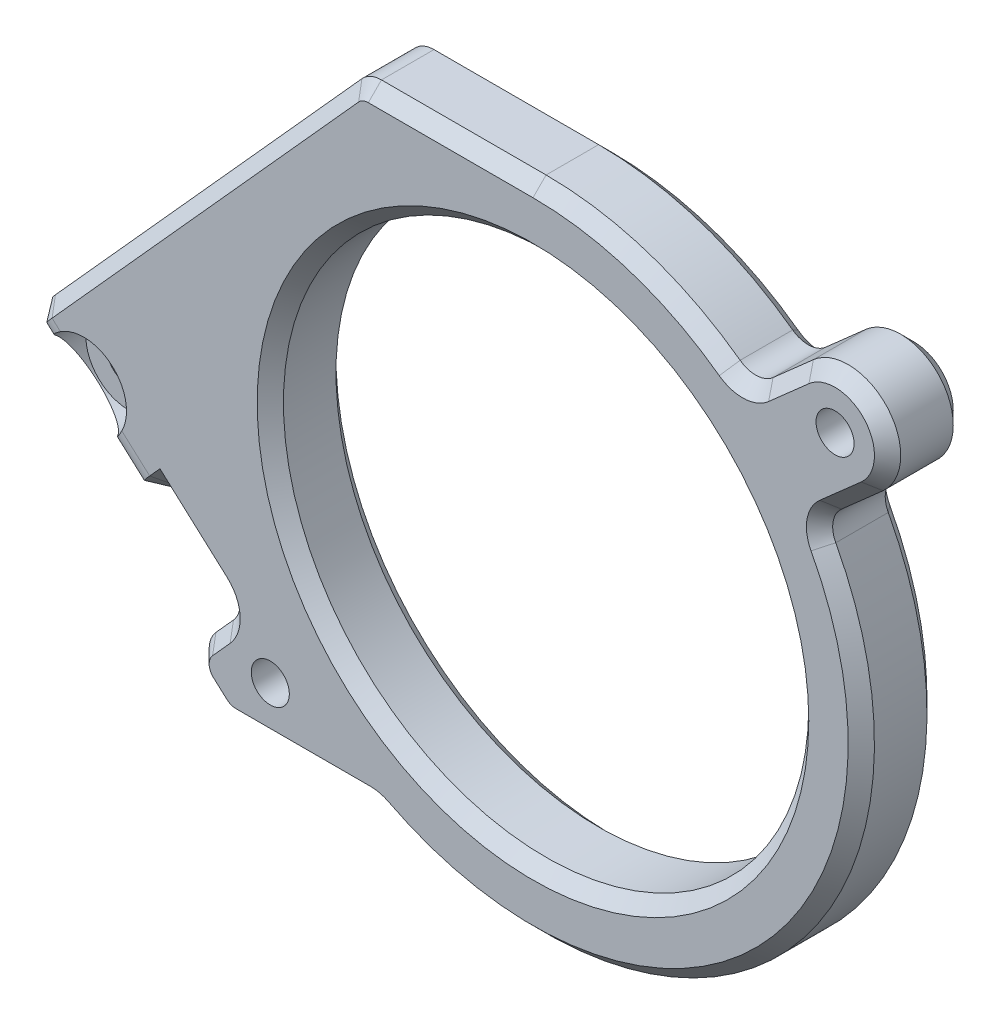
from build123d import *

# Parameters (mm, degrees)
SKETCH_1_W                   = 60
SKETCH_1_H                   = 55
EXTRUDE_1_DEPTH              = 6
HOLE_WIZARD_M4_1_D           = 2.9
HOLE_WIZARD_M4_1_DEPTH       = 10
SKETCH_5_R                   = 20
CUT_EXTRUDE_1_DEPTH          = 7
SKETCH_6_W                   = 60
SKETCH_6_H                   = 55
CUT_EXTRUDE_2_DEPTH          = 7
EXTRUDE_2_DEPTH              = 6
EXTRUDE_3_DEPTH              = 6
EXTRUDE_4_DEPTH              = 4
CUT_EXTRUDE_3_DEPTH          = 11
CUT_EXTRUDE_4_DEPTH          = 6
FILLET_1_R                   = 2
EXTRUDE_5_DEPTH              = 6
CHAMFER_2_SIZE               = 5
FILLET_4_R                   = 2
CHAMFER_3_SIZE               = 1
HOLE_WIZARD_M3_2_D           = 3.3
HOLE_WIZARD_M3_2_DEPTH       = 10
HOLE_WIZARD_M3_2_CBORE_D     = 6.5
HOLE_WIZARD_M3_2_CBORE_DEPTH = 3.4
HOLE_WIZARD_M3_2_TIP         = 0.991420021


with BuildPart() as part:
    # ｽｹｯﾁ1 → ﾎﾞｽ - 押し出し1 (new body)
    with BuildSketch(Plane.XY):
        Rectangle(SKETCH_1_W, SKETCH_1_H)
    extrude(amount=EXTRUDE_1_DEPTH)

    # M4 すきま穴1
    with Locations(Plane.XY.offset(6)):
        with Locations((-20, -18), (23, 20)):
            Hole(HOLE_WIZARD_M4_1_D / 2, depth=HOLE_WIZARD_M4_1_DEPTH)

    # ｽｹｯﾁ5 → ｶｯﾄ - 押し出し1 (cut, through all)
    with BuildSketch(Plane.XY.offset(6)):
        Circle(SKETCH_5_R)
    extrude(amount=-CUT_EXTRUDE_1_DEPTH, mode=Mode.SUBTRACT)

    # ｽｹｯﾁ6 → ｶｯﾄ - 押し出し2 (cut, through all)
    with BuildSketch(Plane.XY.offset(6)):
        Rectangle(SKETCH_6_W, SKETCH_6_H)
        with BuildLine():
            ThreePointArc((-17.351208814, -20.997316342), (-22.997316342, -20.648791186), (-22.648791186, -15.002683658))
            Line((-22.648791186, -15.002683658), (-21.007829355, -13.552531342))
            ThreePointArc((-21.007829355, -13.552531342), (-16.554944912, 18.733227137), (16.03335661, 19.181539975))
            Line((16.03335661, 19.181539975), (20.351208814, 22.997316342))
            ThreePointArc((20.351208814, 22.997316342), (25.997316342, 22.648791186), (25.648791186, 17.002683658))
            Line((25.648791186, 17.002683658), (21.271672672, 13.134532414))
            ThreePointArc((21.271672672, 13.134532414), (24.04986296, 6.826718948), (25, 0))
            ThreePointArc((25, 0), (10.810307191, -22.541900062), (-15.650980674, -19.494789148))
            Line((-15.650980674, -19.494789148), (-17.351208814, -20.997316342))
        make_face(mode=Mode.SUBTRACT)
    extrude(amount=-CUT_EXTRUDE_2_DEPTH, mode=Mode.SUBTRACT)

    # ｽｹｯﾁ7 → ﾎﾞｽ - 押し出し2 (add)
    with BuildSketch(Plane.XY.offset(6)):
        with BuildLine():
            Line((0, 25), (-21.5, 25))
            Line((-21.5, 25), (-21.5, 12.757350822))
            ThreePointArc((-21.5, 12.757350822), (-12.370655388, 21.724798855), (0, 25))
        make_face()
        with BuildLine():
            ThreePointArc((-17.351208814, -20.997316342), (-18.583890076, -21.74094008), (-20, -22))
            Line((-20, -22), (-11.874342087, -22))
            ThreePointArc((-11.874342087, -22), (-13.819546614, -20.833149819), (-15.650980674, -19.494789148))
            Line((-15.650980674, -19.494789148), (-17.351208814, -20.997316342))
        make_face()
        with BuildLine():
            ThreePointArc((-21.007829355, -13.552531342), (-21.25763315, -13.157242601), (-21.5, -12.757350822))
            Line((-21.5, -12.757350822), (-21.5, -13.987472843))
            Line((-21.5, -13.987472843), (-21.007829355, -13.552531342))
        make_face()
    extrude(amount=-EXTRUDE_2_DEPTH)

    # ｽｹｯﾁ8 → ﾎﾞｽ - 押し出し3 (add)
    with BuildSketch(Plane.XY.offset(6)):
        with BuildLine():
            Line((-21.5, 12.757350822), (-21.5, 25))
            Line((-21.5, 25), (-45.717384076, -1.896129831))
            Line((-45.717384076, -1.896129831), (-23.389774269, -22))
            Line((-23.389774269, -22), (-20, -22))
            ThreePointArc((-20, -22), (-23.74094008, -19.416109924), (-22.648791186, -15.002683658))
            Line((-22.648791186, -15.002683658), (-21.5, -13.987472843))
            Line((-21.5, -13.987472843), (-21.5, -12.757350822))
            ThreePointArc((-21.5, -12.757350822), (-25, 0), (-21.5, 12.757350822))
        make_face()
    extrude(amount=-EXTRUDE_3_DEPTH)

    # ｽｹｯﾁ9 → ﾎﾞｽ - 押し出し4 (add)
    with BuildSketch(Plane(origin=(0, 0, 0), x_dir=(-1, 0, 0), z_dir=(0, 0, -1))):
        Polygon((25.649471154, -6.509032491), (32.340777217, -13.940480745), (45.717384076, -1.896129831), (39.026078012, 5.535318424), align=None)
    extrude(amount=EXTRUDE_4_DEPTH)

    # ｽｹｯﾁ10 → ｶｯﾄ - 押し出し3 (cut, through all)
    with BuildSketch(Plane(origin=(0, 0, -4), x_dir=(-1, 0, 0), z_dir=(0, 0, -1))):
        Polygon((39.026078012, 5.535318424), (21.5, 25), (13.426203622, 25), (41.258515123, -5.910913469), (45.717384076, -1.896129831), align=None)
    extrude(amount=-CUT_EXTRUDE_3_DEPTH, mode=Mode.SUBTRACT)

    # ｽｹｯﾁ12 → ｶｯﾄ - 押し出し4 (cut)
    with BuildSketch(Plane.XY.offset(6)):
        Polygon((-41.258515123, -5.910913469), (-26.47934628, -19.218136867), (-22.464562642, -14.759267914), (-37.243731485, -1.452044516), align=None)
    extrude(amount=-CUT_EXTRUDE_4_DEPTH, mode=Mode.SUBTRACT)

    # ﾌｨﾚｯﾄ1
    fillet_1_edges = [part.edges().sort_by_distance(p)[0] for p in [
        (-25.649471154, -6.509032491, -2),
        (-34.567209059, 1.520534786, -2),
        (-26.47934628, -19.218136867, 3),
    ]]
    fillet(fillet_1_edges, radius=FILLET_1_R)

    # ｽｹｯﾁ13 → ﾎﾞｽ - 押し出し5 (add)
    with BuildSketch(Plane.XY):
        Polygon((-32.340777217, -13.940480745), (-28.325993579, -9.481611793), (-37.243731485, -1.452044516), (-41.258515123, -5.910913469), align=None)
    extrude(amount=EXTRUDE_5_DEPTH)

    # 面取り2
    chamfer_2_edges = [part.edges().sort_by_distance(p)[0] for p in [
        (-36.79964617, -9.925697107, 6),
    ]]
    chamfer(chamfer_2_edges, length=CHAMFER_2_SIZE)

    # ﾌｨﾚｯﾄ4
    fillet_4_edges = [part.edges().sort_by_distance(p)[0] for p in [
        (-23.389774269, -22, 3),
        (-13.426203622, 25, 3),
        (-22.464562642, -14.759267914, 3),
        (-33.453993138, -6.20997298, 6),
        (-36.79964617, -9.925697107, 1),
        (21.271672672, 13.134532414, 3),
        (16.03335661, 19.181539975, 3),
        (-11.874342087, -22, 3),
    ]]
    fillet(fillet_4_edges, radius=FILLET_4_R)

    # 面取り3
    chamfer_3_edges = [part.edges().sort_by_distance(p)[0] for p in [
        (-29.664254792, -10.967901443, -4),
        (-32.340777217, -13.940480745, -1.914213562),
        (-36.79964617, -9.925697107, -4),
        (-38.581992697, -2.938334167, -4),
        (-30.108340106, -2.494248852, -4),
        (-34.523852534, 0.693242992, -4),
        (-26.476762948, -6.552389016, -4),
        (-24.471954461, -16.98870239, 6),
        (-24.471954461, -16.98870239, 0),
        (-24.47668202, -21.021343865, 6),
        (-25.652054486, -19.174780341, 6),
        (-25.652054486, -19.174780341, 0),
        (-24.47668202, -21.021343865, 0),
        (-25.690286025, 11.379356601, 6),
        (-28.38339591, -9.54536354, 6),
        (-26.138422936, -11.451309247, 6),
        (-17.495681538, -22, 6),
        (17.805324329, -17.549086174, 6),
        (24.071292776, 15.608615296, 6),
        (18.815379015, 21.640071403, 6),
        (7.771710455, 23.761323966, 6),
        (-13.349219538, 24.827090915, 6),
        (-23.338782098, -21.867160853, 6),
        (-17.495681538, -22, 0),
        (-26.138422936, -11.451309247, 0),
        (-24.963753087, 12.186253174, 0),
        (-6.267873126, 25, 0),
        (7.771710455, 23.761323966, 0),
        (18.815379015, 21.640071403, 0),
        (24.071292776, 15.608615296, 0),
        (17.805324329, -17.549086174, 0),
        (-13.349219538, 24.827090915, 0),
        (-23.338782098, -21.867160853, 0),
        (-41.258515123, -5.910913469, -1.914213562),
        (-39.585688607, -4.053051405, 3.5),
        (-37.870666541, -2.148326436, 5.847759065),
        (-41.156646054, -5.797776406, 0.93693974),
        (-30.667950701, -12.082618682, 3.5),
        (-28.952928635, -10.177893712, 5.847759065),
        (-32.238908148, -13.827343682, 0.93693974),
        (21.8499093, 13.07067214, 0),
        (21.8499093, 13.07067214, 6),
        (16.046656493, 19.783578925, 0),
        (16.046656493, 19.783578925, 6),
        (-11.897912356, -22.056349368, 6),
        (-11.897912356, -22.056349368, 0),
        (-23.291854436, -14.80262444, 6),
        (-23.291854436, -14.80262444, 0),
        (-20, 0, 0),
        (-20, 0, 6),
        (25.997316342, 22.648791186, 0),
        (25.997316342, 22.648791186, 6),
        (-6.267873126, 25, 6),
    ]]
    chamfer(chamfer_3_edges, length=CHAMFER_3_SIZE)

    # M3 六角穴付き頭ねじ用座ぐり穴2
    with Locations(Plane.XY.offset(6)):
        with Locations((-34.197137964, -5.540842373)):
            CounterBoreHole(HOLE_WIZARD_M3_2_D / 2, HOLE_WIZARD_M3_2_CBORE_D / 2, HOLE_WIZARD_M3_2_CBORE_DEPTH, depth=HOLE_WIZARD_M3_2_DEPTH)
            with Locations((0, 0, -(HOLE_WIZARD_M3_2_DEPTH + HOLE_WIZARD_M3_2_TIP / 2))):  # 118° drill point
                Cone(0, HOLE_WIZARD_M3_2_D / 2, HOLE_WIZARD_M3_2_TIP, mode=Mode.SUBTRACT)


solid = part.part
